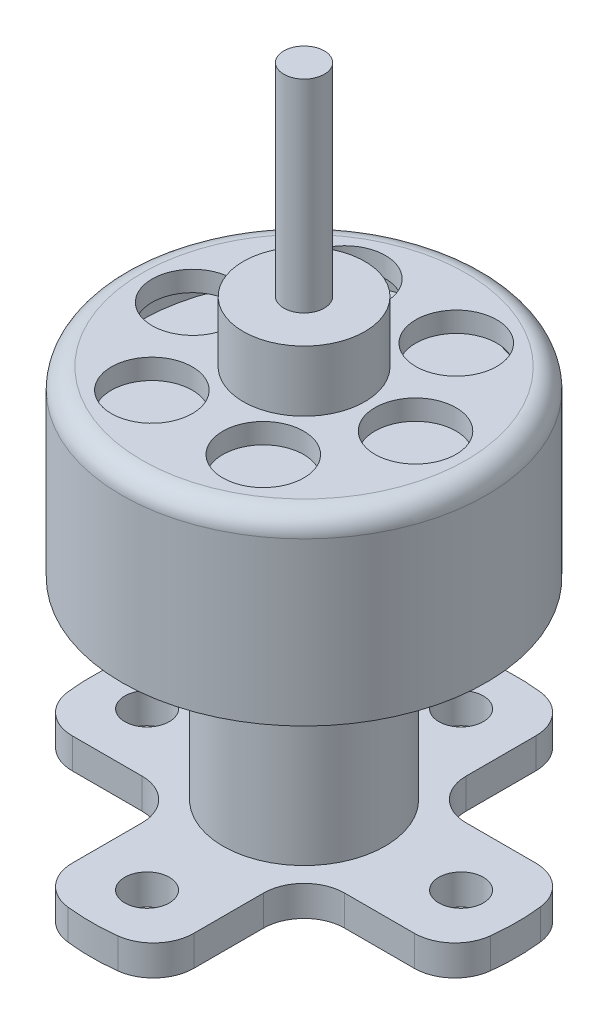
from build123d import *

# Parameters (mm, degrees)
BOSS_EXTRUDE1_DEPTH = 1.5
SKETCH2_R           = 1.1
CUT_EXTRUDE1_DEPTH  = 2.5
FILLET1_R           = 2
SKETCH3_R           = 4
BOSS_EXTRUDE2_DEPTH = 9.5
SKETCH4_R           = 9
BOSS_EXTRUDE3_DEPTH = 9
FILLET2_R           = 1
SKETCH5_R           = 3
BOSS_EXTRUDE4_DEPTH = 3
SKETCH6_R           = 1
BOSS_EXTRUDE5_DEPTH = 10
SKETCH7_R           = 2
CUT_EXTRUDE2_DEPTH  = 1
SKETCH8_R           = 8
CUT_EXTRUDE3_DEPTH  = 1


with BuildPart() as part:
    # Sketch1 → Boss-Extrude1 (new body)
    with BuildSketch(Plane(origin=(0, 0, 0), x_dir=(1, 0, 0), z_dir=(0, 1, 0))):
        with BuildLine():
            Line((-3, 10.062305899), (-3, 3))
            Line((-3, 3), (-10.062305899, 3))
            ThreePointArc((-10.062305899, 3), (-10.5, 0), (-10.062305899, -3))
            Line((-10.062305899, -3), (-3, -3))
            Line((-3, -3), (-3, -10.062305899))
            ThreePointArc((-3, -10.062305899), (0, -10.5), (3, -10.062305899))
            Line((3, -10.062305899), (3, -3))
            Line((3, -3), (10.062305899, -3))
            ThreePointArc((10.062305899, -3), (10.5, 0), (10.062305899, 3))
            Line((10.062305899, 3), (3, 3))
            Line((3, 3), (3, 10.062305899))
            ThreePointArc((3, 10.062305899), (0, 10.5), (-3, 10.062305899))
        make_face()
    extrude(amount=BOSS_EXTRUDE1_DEPTH)

    # Sketch2 → Cut-Extrude1 (cut, through all)
    with BuildSketch(Plane(origin=(0, 1.5, 0), x_dir=(1, 0, 0), z_dir=(0, 1, 0))):
        with Locations((-7.75, 0)):
            Circle(SKETCH2_R)
        with Locations((0, 7.75)):
            Circle(SKETCH2_R)
        with Locations((7.75, 0)):
            Circle(SKETCH2_R)
        with Locations((0, -7.75)):
            Circle(SKETCH2_R)
    extrude(amount=-CUT_EXTRUDE1_DEPTH, mode=Mode.SUBTRACT)

    # Fillet1
    fillet1_edges = [part.edges().sort_by_distance(p)[0] for p in [
        (3, 0.75, 3),
        (3, 0.75, 10.062305899),
        (-3, 0.75, 10.062305899),
        (-3, 0.75, 3),
        (-10.062305899, 0.75, 3),
        (-10.062305899, 0.75, -3),
        (-3, 0.75, -3),
        (-3, 0.75, -10.062305899),
        (3, 0.75, -10.062305899),
        (3, 0.75, -3),
        (10.062305899, 0.75, -3),
        (10.062305899, 0.75, 3),
    ]]
    fillet(fillet1_edges, radius=FILLET1_R)

    # Sketch3 → Boss-Extrude2 (add)
    with BuildSketch(Plane(origin=(0, 1.5, 0), x_dir=(1, 0, 0), z_dir=(0, 1, 0))):
        Circle(SKETCH3_R)
    extrude(amount=BOSS_EXTRUDE2_DEPTH)

    # Sketch4 → Boss-Extrude3 (add)
    with BuildSketch(Plane(origin=(0, 11, 0), x_dir=(1, 0, 0), z_dir=(0, 1, 0))):
        Circle(SKETCH4_R)
    extrude(amount=BOSS_EXTRUDE3_DEPTH)

    # Fillet2
    fillet2_edges = [part.edges().sort_by_distance(p)[0] for p in [
        (-9, 20, 0),
    ]]
    fillet(fillet2_edges, radius=FILLET2_R)

    # Sketch5 → Boss-Extrude4 (add)
    with BuildSketch(Plane(origin=(0, 20, 0), x_dir=(1, 0, 0), z_dir=(0, 1, 0))):
        Circle(SKETCH5_R)
    extrude(amount=BOSS_EXTRUDE4_DEPTH)

    # Sketch6 → Boss-Extrude5 (add)
    with BuildSketch(Plane(origin=(0, 23, 0), x_dir=(1, 0, 0), z_dir=(0, 1, 0))):
        Circle(SKETCH6_R)
    extrude(amount=BOSS_EXTRUDE5_DEPTH)

    # Sketch7 → Cut-Extrude2 (cut)
    with BuildSketch(Plane(origin=(0, 20, 0), x_dir=(1, 0, 0), z_dir=(0, 1, 0))):
        with Locations((-5.5, 0)):
            Circle(SKETCH7_R)
        with Locations((-2.75, 4.763139721)):
            Circle(SKETCH7_R)
        with Locations((2.75, 4.763139721)):
            Circle(SKETCH7_R)
        with Locations((5.5, 0)):
            Circle(SKETCH7_R)
        with Locations((2.75, -4.763139721)):
            Circle(SKETCH7_R)
        with Locations((-2.75, -4.763139721)):
            Circle(SKETCH7_R)
    extrude(amount=-CUT_EXTRUDE2_DEPTH, mode=Mode.SUBTRACT)

    # Sketch8 → Cut-Extrude3 (cut)
    with BuildSketch(Plane(origin=(0, 19, 0), x_dir=(1, 0, 0), z_dir=(0, 1, 0))):
        Circle(SKETCH8_R)
    extrude(amount=-CUT_EXTRUDE3_DEPTH, mode=Mode.SUBTRACT)


solid = part.part
